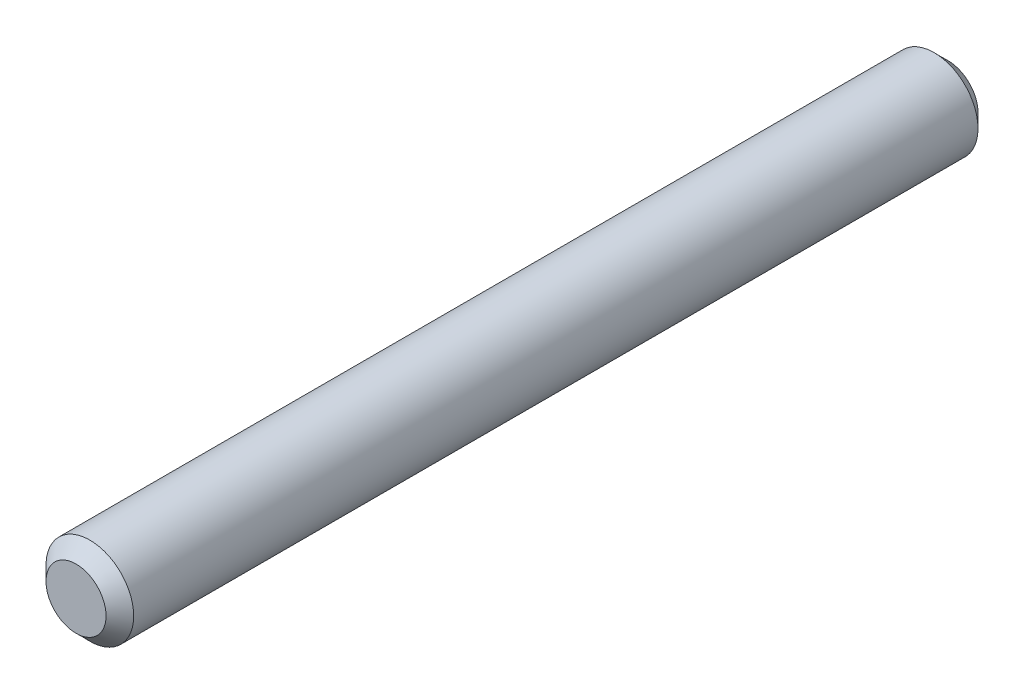
from build123d import *

# Parameters (mm, degrees)
SKETCH1_R           = 3.175
BOSS_EXTRUDE1_DEPTH = 63.141999954
CHAMFER1_SIZE       = 1


with BuildPart() as part:
    # Sketch1 → Boss-Extrude1 (new body)
    with BuildSketch(Plane.XY):
        Circle(SKETCH1_R)
    extrude(amount=-BOSS_EXTRUDE1_DEPTH)

    # Chamfer1
    chamfer1_edges = [part.edges().sort_by_distance(p)[0] for p in [
        (-3.175, 0, 0),
        (-3.175, 0, -63.141999954),
    ]]
    chamfer(chamfer1_edges, length=CHAMFER1_SIZE)


solid = part.part
